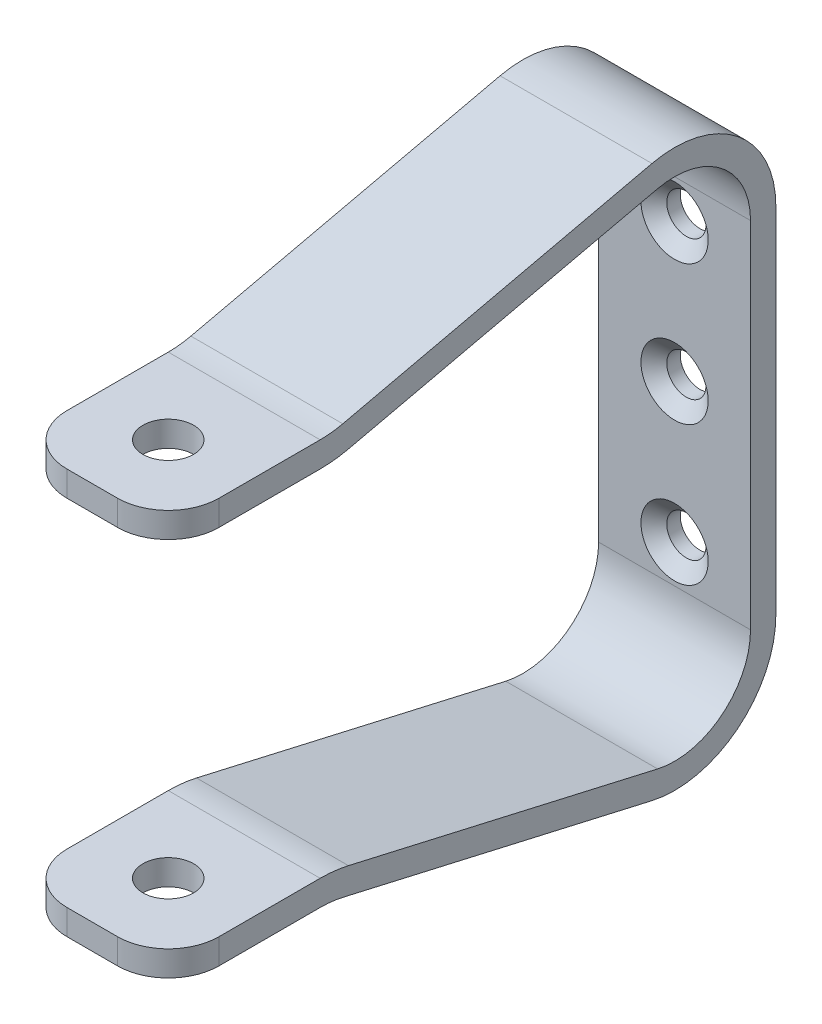
from build123d import *

# Parameters (mm, degrees)
EXTRUDE_THIN1_DEPTH                       = 9.525
SKETCH4_R                                 = 3.175
CUT_EXTRUDE1_DEPTH                        = 61.325
CSK_FOR_8_FLAT_HEAD_MACHINE_SCREW_2_COUNT = 2
CSK_FOR_8_FLAT_HEAD_MACHINE_SCREW_2_PITCH = 17.4625
CSK_FOR_8_FLAT_HEAD_MACHINE_SCREW_3_COUNT = 2
CSK_FOR_8_FLAT_HEAD_MACHINE_SCREW_3_PITCH = 34.925
FILLET1_R                                 = 6.35


with BuildPart() as part:
    # Sketch2 → Extrude-Thin1 (new body, symmetric)
    with BuildSketch(Plane(origin=(0, 0, 66.675), x_dir=(0, -1, 0), z_dir=(1, 0, 0))):
        with BuildLine():
            Line((22.225, 66.675), (-22.225, 66.675))
            ThreePointArc((-22.225, 66.675), (-32.15743925, 61.88933197), (-34.604310473, 51.139039455))
            Line((-34.604310473, 51.139039455), (-25.720689527, 12.360960545))
            ThreePointArc((-25.720689527, 12.360960545), (-25.480427048, 10.952017343), (-25.4, 9.525))
            Line((-25.4, 9.525), (-25.4, -9.525))
            Line((-25.4, -9.525), (-22.225, -9.525))
            Line((-22.225, -9.525), (-22.225, 9.525))
            ThreePointArc((-22.225, 9.525), (-22.325533809, 11.308771679), (-22.625861909, 13.069950682))
            Line((-22.625861909, 13.069950682), (-31.509482855, 51.848029591))
            ThreePointArc((-31.509482855, 51.848029591), (-29.674329438, 59.910748978), (-22.225, 63.5))
            Line((-22.225, 63.5), (22.225, 63.5))
            Line((22.225, 63.5), (22.225, 66.675))
        make_face()
    extrude_thin1 = extrude(amount=EXTRUDE_THIN1_DEPTH, both=True)

    # Mirror1: Extrude-Thin1 across plane
    add(extrude_thin1.mirror(Plane.ZX))

    # Sketch4 → Cut-Extrude1 (cut, through all)
    with BuildSketch(Plane.XZ.offset(25.4)):
        with Locations((0, 66.675)):
            Circle(SKETCH4_R)
    extrude(amount=-CUT_EXTRUDE1_DEPTH, mode=Mode.SUBTRACT)

    # Sketch6 → CSK for #8 Flat Head Machine Screw (100)1 (revolve, cut)
    with BuildSketch(Plane(origin=(0, -17.4625, 3.175), x_dir=(0, -1, 0), z_dir=(1, 0, 0))):
        Polygon((0, 0), (0, 3.175), (2.45745, 3.175), (2.45745, 1.475934296), (4.2164, 0), align=None)
    csk_for_8_flat_head_machine_screw_100 = revolve(axis=Axis((0, -17.4625, 9.525), (0, 0, -1)), mode=Mode.SUBTRACT)

    # CSK for _8 Flat Head Machine Screw _ 2: CSK for #8 Flat Head Machine Screw (100)1 ×2
    with Locations(*[(0, i * CSK_FOR_8_FLAT_HEAD_MACHINE_SCREW_2_PITCH, 0) for i in range(1, CSK_FOR_8_FLAT_HEAD_MACHINE_SCREW_2_COUNT)]):
        add(csk_for_8_flat_head_machine_screw_100, mode=Mode.SUBTRACT)

    # CSK for _8 Flat Head Machine Screw _ 3: CSK for #8 Flat Head Machine Screw (100)1 ×2
    with Locations(*[(0, i * CSK_FOR_8_FLAT_HEAD_MACHINE_SCREW_3_PITCH, 0) for i in range(1, CSK_FOR_8_FLAT_HEAD_MACHINE_SCREW_3_COUNT)]):
        add(csk_for_8_flat_head_machine_screw_100, mode=Mode.SUBTRACT)

    # Fillet1
    fillet1_edges = [part.edges().sort_by_distance(p)[0] for p in [
        (-9.525, 23.8125, 76.2),
        (9.525, -23.8125, 76.2),
        (-9.525, -23.8125, 76.2),
        (9.525, 23.8125, 76.2),
    ]]
    fillet(fillet1_edges, radius=FILLET1_R)


solid = part.part
